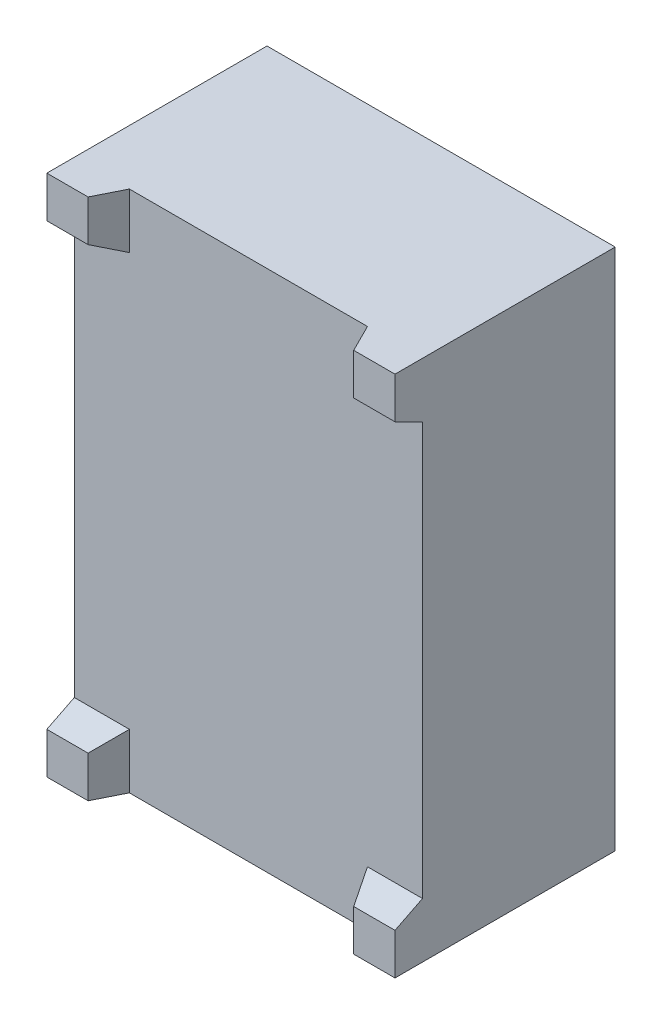
from build123d import *

# Parameters (mm, degrees)
IZIM1_W                       = 12.65
IZIM1_H                       = 19
Y_KSEKLIK_EKSTR_ZYON1_DEPTH   = 7.75
KES_EKSTR_ZYON1_DEPTH         = 20
KES_EKSTR_ZYON2_DEPTH         = 13.65
IZIM4_W                       = 12.35
IZIM4_H                       = 18.7
IZIM4_R                       = 0.75
Y_KSEKLIK_EKSTR_ZYON2_DEPTH   = 0.25
IZIM5_R                       = 0.75
Y_KSEKLIK_EKSTR_ZYON3_DEPTH   = 0.25
Y_KSEKLIK_EKSTR_ZYON3_2_DEPTH = 0.25
Y_KSEKLIK_EKSTR_ZYON3_3_DEPTH = 0.25
Y_KSEKLIK_EKSTR_ZYON3_4_DEPTH = 0.25
Y_KSEKLIK_EKSTR_ZYON3_5_DEPTH = 0.25
Y_KSEKLIK_EKSTR_ZYON3_6_DEPTH = 0.25
Y_KSEKLIK_EKSTR_ZYON3_7_DEPTH = 0.25
Y_KSEKLIK_EKSTR_ZYON3_8_DEPTH = 0.25
IZIM6_W                       = 12.65
IZIM6_H                       = 19
IZIM6_W_2                     = 12.35
IZIM6_H_2                     = 18.7
Y_KSEKLIK_EKSTR_ZYON4_DEPTH   = 0.25


with BuildPart() as part:
    # Çizim1 → Yükseklik-Ekstrüzyon1 (new body)
    with BuildSketch(Plane.XY):
        Rectangle(IZIM1_W, IZIM1_H)
    extrude(amount=Y_KSEKLIK_EKSTR_ZYON1_DEPTH)

    # Çizim2 → Kes-Ekstrüzyon1 (cut, through all)
    with BuildSketch(Plane(origin=(0, 9.5, 0), x_dir=(1, 0, 0), z_dir=(0, 1, 0))):
        Polygon((-4.325, -6.75), (-4.825, -7.75), (4.825, -7.75), (4.325, -6.75), align=None)
    extrude(amount=-KES_EKSTR_ZYON1_DEPTH, mode=Mode.SUBTRACT)

    # Çizim3 → Kes-Ekstrüzyon2 (cut, through all)
    with BuildSketch(Plane.ZY.offset(6.325)):
        Polygon((7.75, 8), (6.75, 7.5), (6.75, -7.5), (7.75, -8), align=None)
    extrude(amount=-KES_EKSTR_ZYON2_DEPTH, mode=Mode.SUBTRACT)



with BuildPart() as body_2:
    # Çizim4 → Yükseklik-Ekstrüzyon2 (new body)
    with BuildSketch(Plane(origin=(0, 0, 0), x_dir=(-1, 0, 0), z_dir=(0, 0, -1))):
        with Locations((0, 0.008624693)):
            Rectangle(IZIM4_W, IZIM4_H)
        with Locations((4.975, -6.091375307)):
            Circle(IZIM4_R, mode=Mode.SUBTRACT)
        with BuildLine():
            Line((5.00792639, 5.714170462), (4.246733621, 0.5))
            Line((4.246733621, 0.5), (3.746733621, 0.5))
            Line((3.746733621, 0.5), (2.878348659, 1.401563009))
            Line((2.878348659, 1.401563009), (3.675, 6.858624693))
            Line((3.675, 6.858624693), (4.018414907, 6.858624693))
            ThreePointArc((4.018414907, 6.858624693), (4.774871855, 6.512668181), (5.00792639, 5.714170462))
        make_face(mode=Mode.SUBTRACT)
        with BuildLine():
            Line((1.675, -6.841375307), (2.310385709, -6.841375307))
            ThreePointArc((2.310385709, -6.841375307), (2.964429198, -6.597832256), (3.299897193, -5.985829538))
            Line((3.299897193, -5.985829538), (4.10074822, -0.5))
            Line((4.10074822, -0.5), (3.60074822, -0.5))
            Line((3.60074822, -0.5), (2.491259169, -1.25))
            Line((2.491259169, -1.25), (1.675, -6.841375307))
        make_face(mode=Mode.SUBTRACT)
        with BuildLine():
            Line((-3.299897193, 6.003078924), (-4.103266379, 0.5))
            Line((-4.103266379, 0.5), (-3.603266379, 0.5))
            Line((-3.603266379, 0.5), (-2.506640402, 1.161887938))
            Line((-2.506640402, 1.161887938), (-1.675, 6.858624693))
            Line((-1.675, 6.858624693), (-2.310385709, 6.858624693))
            ThreePointArc((-2.310385709, 6.858624693), (-2.964429198, 6.615081642), (-3.299897193, 6.003078924))
        make_face(mode=Mode.SUBTRACT)
        with BuildLine():
            Line((-5.00792639, -5.696921076), (-4.24925178, -0.5))
            Line((-4.24925178, -0.5), (-3.74925178, -0.5))
            Line((-3.74925178, -0.5), (-2.858740831, -1.25))
            Line((-2.858740831, -1.25), (-3.675, -6.841375307))
            Line((-3.675, -6.841375307), (-4.018414907, -6.841375307))
            ThreePointArc((-4.018414907, -6.841375307), (-4.774871855, -6.495418795), (-5.00792639, -5.696921076))
        make_face(mode=Mode.SUBTRACT)
        Polygon((-3.071994015, -5.341375307), (-3.290972117, -6.841375307), (1.290972117, -6.841375307), (1.509950219, -5.341375307), align=None, mode=Mode.SUBTRACT)
        Polygon((-2.506640402, 0.75), (2.878348659, 0.75), (3.60074822, 0), (2.491259169, -0.75), (-2.858740831, -0.75), (-3.74925178, 0), align=None, mode=Mode.SUBTRACT)
        Polygon((-1.290972117, 6.858624693), (-1.509950219, 5.358624693), (3.071994015, 5.358624693), (3.290972117, 6.858624693), align=None, mode=Mode.SUBTRACT)
    extrude(amount=Y_KSEKLIK_EKSTR_ZYON2_DEPTH)


with BuildPart() as body_3:
    # Çizim5 → Yükseklik-Ekstrüzyon3 (new body)
    with BuildSketch(Plane(origin=(0, 0, -0.25), x_dir=(-1, 0, 0), z_dir=(0, 0, -1))):
        with Locations((4.975, -6.091375307)):
            Circle(IZIM5_R)
    extrude(amount=-Y_KSEKLIK_EKSTR_ZYON3_DEPTH)


with BuildPart() as body_4:
    # Çizim5 → Y_kseklik-Ekstr_zyon3 2 (new body)
    with BuildSketch(Plane(origin=(0, 0, -0.25), x_dir=(-1, 0, 0), z_dir=(0, 0, -1))):
        Polygon((3.290972117, 6.858624693), (-1.290972117, 6.858624693), (-1.509950219, 5.358624693), (3.071994015, 5.358624693), align=None)
    extrude(amount=-Y_KSEKLIK_EKSTR_ZYON3_2_DEPTH)


with BuildPart() as body_5:
    # Çizim5 → Y_kseklik-Ekstr_zyon3 3 (new body)
    with BuildSketch(Plane(origin=(0, 0, -0.25), x_dir=(-1, 0, 0), z_dir=(0, 0, -1))):
        with BuildLine():
            Line((-2.506640402, 1.161887938), (-1.675, 6.858624693))
            Line((-1.675, 6.858624693), (-2.310385709, 6.858624693))
            ThreePointArc((-2.310385709, 6.858624693), (-2.964429198, 6.615081642), (-3.299897193, 6.003078924))
            Line((-3.299897193, 6.003078924), (-4.103266379, 0.5))
            Line((-4.103266379, 0.5), (-3.603266379, 0.5))
            Line((-3.603266379, 0.5), (-2.506640402, 1.161887938))
        make_face()
    extrude(amount=-Y_KSEKLIK_EKSTR_ZYON3_3_DEPTH)


with BuildPart() as body_6:
    # Çizim5 → Y_kseklik-Ekstr_zyon3 4 (new body)
    with BuildSketch(Plane(origin=(0, 0, -0.25), x_dir=(-1, 0, 0), z_dir=(0, 0, -1))):
        Polygon((-2.506640402, 0.75), (-3.74925178, 0), (-2.858740831, -0.75), (2.491259169, -0.75), (3.60074822, 0), (2.878348659, 0.75), align=None)
    extrude(amount=-Y_KSEKLIK_EKSTR_ZYON3_4_DEPTH)


with BuildPart() as body_7:
    # Çizim5 → Y_kseklik-Ekstr_zyon3 5 (new body)
    with BuildSketch(Plane(origin=(0, 0, -0.25), x_dir=(-1, 0, 0), z_dir=(0, 0, -1))):
        with BuildLine():
            Line((-2.858740831, -1.25), (-3.74925178, -0.5))
            Line((-3.74925178, -0.5), (-4.24925178, -0.5))
            Line((-4.24925178, -0.5), (-5.00792639, -5.696921076))
            ThreePointArc((-5.00792639, -5.696921076), (-4.774871855, -6.495418795), (-4.018414907, -6.841375307))
            Line((-4.018414907, -6.841375307), (-3.675, -6.841375307))
            Line((-3.675, -6.841375307), (-2.858740831, -1.25))
        make_face()
    extrude(amount=-Y_KSEKLIK_EKSTR_ZYON3_5_DEPTH)


with BuildPart() as body_8:
    # Çizim5 → Y_kseklik-Ekstr_zyon3 6 (new body)
    with BuildSketch(Plane(origin=(0, 0, -0.25), x_dir=(-1, 0, 0), z_dir=(0, 0, -1))):
        with BuildLine():
            Line((3.675, 6.858624693), (2.878348659, 1.401563009))
            Line((2.878348659, 1.401563009), (3.746733621, 0.5))
            Line((3.746733621, 0.5), (4.246733621, 0.5))
            Line((4.246733621, 0.5), (5.00792639, 5.714170462))
            ThreePointArc((5.00792639, 5.714170462), (4.774871855, 6.512668181), (4.018414907, 6.858624693))
            Line((4.018414907, 6.858624693), (3.675, 6.858624693))
        make_face()
    extrude(amount=-Y_KSEKLIK_EKSTR_ZYON3_6_DEPTH)


with BuildPart() as body_9:
    # Çizim5 → Y_kseklik-Ekstr_zyon3 7 (new body)
    with BuildSketch(Plane(origin=(0, 0, -0.25), x_dir=(-1, 0, 0), z_dir=(0, 0, -1))):
        with BuildLine():
            Line((3.60074822, -0.5), (2.491259169, -1.25))
            Line((2.491259169, -1.25), (1.675, -6.841375307))
            Line((1.675, -6.841375307), (2.310385709, -6.841375307))
            ThreePointArc((2.310385709, -6.841375307), (2.964429198, -6.597832256), (3.299897193, -5.985829538))
            Line((3.299897193, -5.985829538), (4.10074822, -0.5))
            Line((4.10074822, -0.5), (3.60074822, -0.5))
        make_face()
    extrude(amount=-Y_KSEKLIK_EKSTR_ZYON3_7_DEPTH)


with BuildPart() as body_10:
    # Çizim5 → Y_kseklik-Ekstr_zyon3 8 (new body)
    with BuildSketch(Plane(origin=(0, 0, -0.25), x_dir=(-1, 0, 0), z_dir=(0, 0, -1))):
        Polygon((-3.071994015, -5.341375307), (-3.290972117, -6.841375307), (1.290972117, -6.841375307), (1.509950219, -5.341375307), align=None)
    extrude(amount=-Y_KSEKLIK_EKSTR_ZYON3_8_DEPTH)


with BuildPart() as part_1:
    add(part.part)

    add(body_2.part)  # Yükseklik-Ekstrüzyon4 merges body 2
    # Çizim6 → Yükseklik-Ekstrüzyon4 (add, through all)
    with BuildSketch(Plane(origin=(0, 0, 0), x_dir=(-1, 0, 0), z_dir=(0, 0, -1))):
        Rectangle(IZIM6_W, IZIM6_H)
        with Locations((0, 0.008624693)):
            Rectangle(IZIM6_W_2, IZIM6_H_2, mode=Mode.SUBTRACT)
    extrude(amount=Y_KSEKLIK_EKSTR_ZYON4_DEPTH)


solid = Compound([body_3.part, body_4.part, body_5.part, body_6.part, body_7.part, body_8.part, body_9.part, body_10.part, part_1.part])
